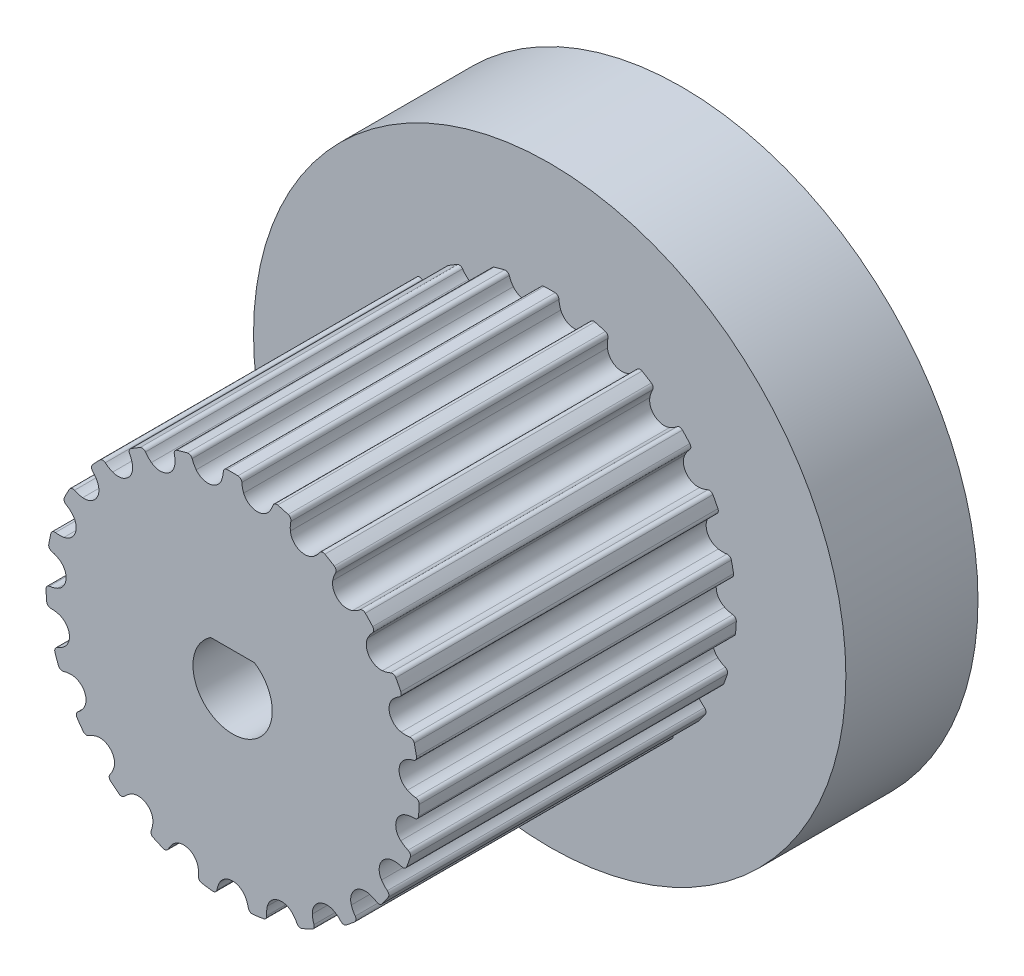
from build123d import *

# Parameters (mm, degrees)
SKETCH1_R               = 7.067127382
BOSS_EXTRUDE1_DEPTH     = 12
CUT_EXTRUDE1_DEPTH      = 13
CIRPATTERN5_COUNT       = 23
CORTAR_EXTRUIR1_DEPTH   = 6
CROQUIS2_R              = 11.208843687
SALIENTE_EXTRUIR1_DEPTH = 5


with BuildPart() as part:
    # Sketch1 → Boss-Extrude1 (new body)
    with BuildSketch(Plane.XY):
        Circle(SKETCH1_R)
    extrude(amount=BOSS_EXTRUDE1_DEPTH)

    # Sketch2 → Cut-Extrude1 (cut, through all)
    with BuildSketch(Plane.XY.offset(12)):
        with BuildLine():
            ThreePointArc((0.350892732, 6.921687277), (0.306034863, 7.021369263), (0.205439978, 7.064140702))
            ThreePointArc((0.205439978, 7.064140702), (0.962307054, 7.001303776), (1.708060646, 6.857610245))
            ThreePointArc((1.708060646, 6.857610245), (1.599656496, 6.843565062), (1.529568201, 6.759682063))
            ThreePointArc((1.529568201, 6.759682063), (1.465425991, 6.609914236), (1.37781524, 6.472549825))
            ThreePointArc((1.37781524, 6.472549825), (0.860182068, 6.258289317), (0.419550931, 6.604260223))
            ThreePointArc((0.419550931, 6.604260223), (0.372249499, 6.760167887), (0.350892732, 6.921687277))
        make_face()
    cut_extrude1 = extrude(amount=-CUT_EXTRUDE1_DEPTH, mode=Mode.SUBTRACT)

    # CirPattern5: Cut-Extrude1 ×23 about axis
    cirpattern5_axis = Axis((0, 0, 0), (0, 0, 1))
    for i in range(1, CIRPATTERN5_COUNT):
        add(cut_extrude1.rotate(cirpattern5_axis, i * 360 / CIRPATTERN5_COUNT), mode=Mode.SUBTRACT)

    # Croquis1 → Cortar-Extruir1 (cut)
    with BuildSketch(Plane.XY.offset(12)):
        with BuildLine():
            Line((-0.829156198, 1.25), (0.829156198, 1.25))
            ThreePointArc((0.829156198, 1.25), (0, -1.5), (-0.829156198, 1.25))
        make_face()
    extrude(amount=-CORTAR_EXTRUIR1_DEPTH, mode=Mode.SUBTRACT)

    # Croquis2 → Saliente-Extruir1 (add)
    with BuildSketch(Plane(origin=(0, 0, 0), x_dir=(-1, 0, 0), z_dir=(0, 0, -1))):
        Circle(CROQUIS2_R)
    extrude(amount=SALIENTE_EXTRUIR1_DEPTH)


solid = part.part
